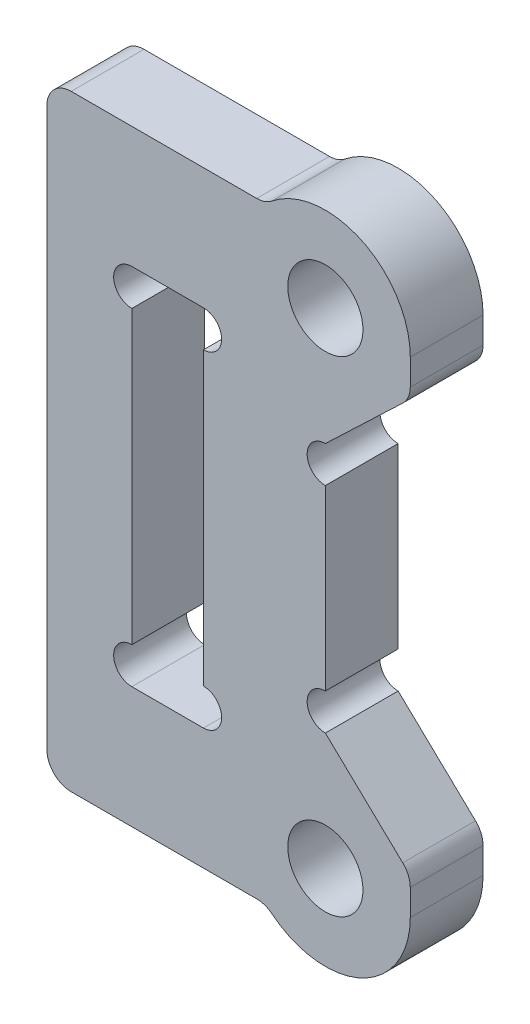
from build123d import *

# Parameters (mm, degrees)
SKETCH_1_R          = 1.55
SKETCH_1_W          = 2.95
SKETCH_1_H          = 15
EXTRUDE_1_DEPTH     = 1.5
FILLET_1_R          = 1
SKETCH_2_R          = 0.75
CUT_EXTRUDE_1_DEPTH = 4
CUT_EXTRUDE_2_DEPTH = 4
SKETCH_4_R          = 0.75
CUT_EXTRUDE_3_DEPTH = 4
FILLET_2_R          = 1


with BuildPart() as part:
    # 草图1 → 凸台-拉伸1 (new body, symmetric)
    with BuildSketch(Plane.XY):
        with BuildLine():
            Line((-2.449489743, 12.5), (-11.475, 12.5))
            Line((-11.475, 12.5), (-11.475, -12.5))
            Line((-11.475, -12.5), (-2.449489743, -12.5))
            ThreePointArc((-2.449489743, -12.5), (1.355873501, -13.226702194), (3.5, -10))
            Line((3.5, -10), (3.5, 10))
            ThreePointArc((3.5, 10), (1.355873501, 13.226702194), (-2.449489743, 12.5))
        make_face()
        with Locations((0, 10)):
            Circle(SKETCH_1_R, mode=Mode.SUBTRACT)
        with Locations((0, -10)):
            Circle(SKETCH_1_R, mode=Mode.SUBTRACT)
        with Locations((-6.5, 0)):
            Rectangle(SKETCH_1_W, SKETCH_1_H, mode=Mode.SUBTRACT)
    extrude(amount=EXTRUDE_1_DEPTH, both=True)

    # 圆角1
    fillet_1_edges = [part.edges().sort_by_distance(p)[0] for p in [
        (-11.475, -12.5, 0),
        (-11.475, 12.5, 0),
    ]]
    fillet(fillet_1_edges, radius=FILLET_1_R)

    # 草图2 → 切除-拉伸1 (cut, through all)
    with BuildSketch(Plane.XY.offset(1.5)):
        with Locations((-7.975, 6.75)):
            Circle(SKETCH_2_R)
        with Locations((-5.025, 6.75)):
            Circle(SKETCH_2_R)
        with Locations((-7.975, -6.75)):
            Circle(SKETCH_2_R)
        with Locations((-5.025, -6.75)):
            Circle(SKETCH_2_R)
    extrude(amount=-CUT_EXTRUDE_1_DEPTH, mode=Mode.SUBTRACT)

    # 草图3 → 切除-拉伸2 (cut, through all)
    with BuildSketch(Plane.XY.offset(1.5)):
        Polygon((3.5, 8.5), (0, 5.166666667), (0, -5.166666667), (3.5, -8.5), align=None)
    extrude(amount=-CUT_EXTRUDE_2_DEPTH, mode=Mode.SUBTRACT)

    # 草图4 → 切除-拉伸3 (cut, through all)
    with BuildSketch(Plane.XY.offset(1.5)):
        with Locations((0, 4.416666667)):
            Circle(SKETCH_4_R)
        with Locations((0, -4.416666667)):
            Circle(SKETCH_4_R)
    extrude(amount=-CUT_EXTRUDE_3_DEPTH, mode=Mode.SUBTRACT)

    # 圆角2
    fillet_2_edges = [part.edges().sort_by_distance(p)[0] for p in [
        (-2.449489743, 12.5, 0),
        (-2.449489743, -12.5, 0),
        (3.5, 8.5, 0),
        (3.5, -8.5, 0),
    ]]
    fillet(fillet_2_edges, radius=FILLET_2_R)


solid = part.part
